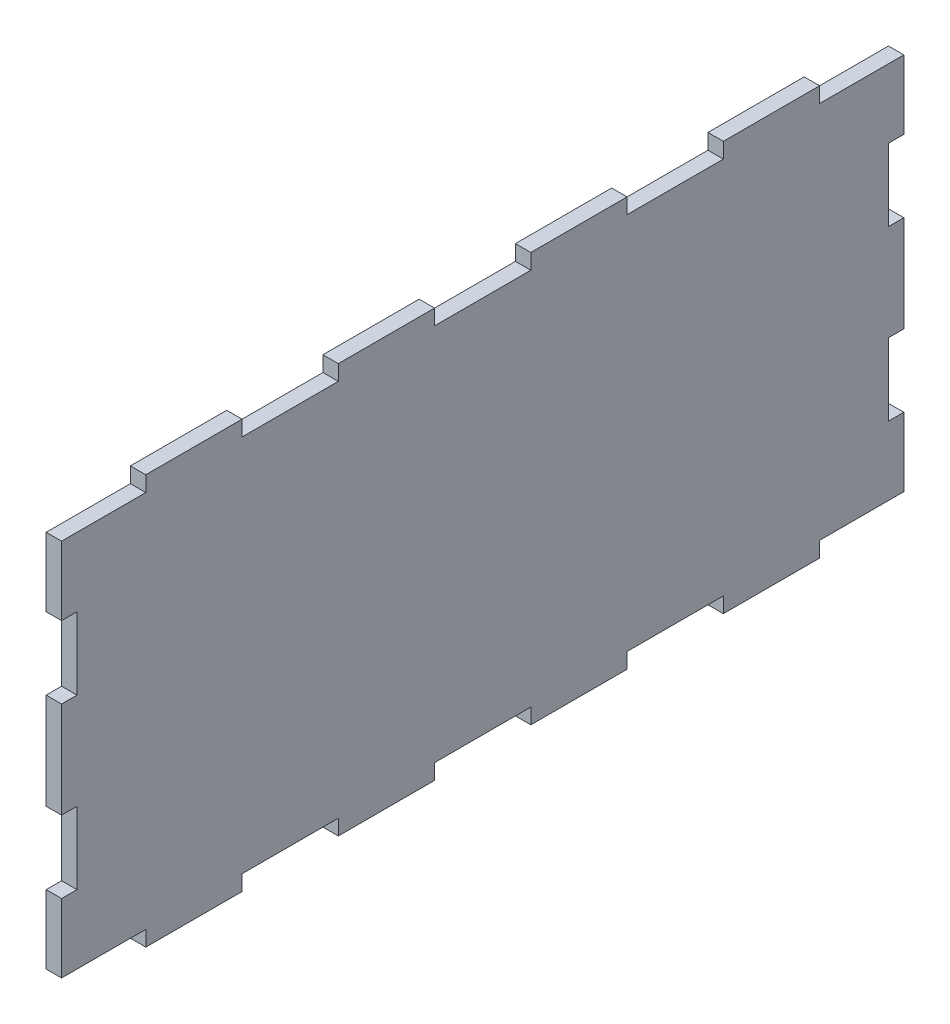
from build123d import *

# Parameters (mm, degrees)
BOSS_EXTRUDE1_DEPTH = 3.2


with BuildPart() as part:
    # Sketch1 → Boss-Extrude1 (new body)
    with BuildSketch(Plane(origin=(0, 0, 0), x_dir=(0, 0, -1), z_dir=(1, 0, 0))):
        Polygon((-10, 42.5), (-30, 42.5), (-30, 39.3), (-50, 39.3), (-50, 42.5), (-70, 42.5), (-70, 39.3), (-87.5, 39.3), (-87.5, 25), (-84.3, 25), (-84.3, 10), (-87.5, 10), (-87.5, -10), (-84.3, -10), (-84.3, -25), (-87.5, -25), (-87.5, -39.3), (-70, -39.3), (-70, -42.5), (-50, -42.5), (-50, -39.3), (-30, -39.3), (-30, -42.5), (-10, -42.5), (-10, -39.3), (10, -39.3), (10, -42.5), (30, -42.5), (30, -39.3), (50, -39.3), (50, -42.5), (70, -42.5), (70, -39.3), (87.5, -39.3), (87.5, -25), (84.3, -25), (84.3, -10), (87.5, -10), (87.5, 10), (84.3, 10), (84.3, 25), (87.5, 25), (87.5, 39.3), (70, 39.3), (70, 42.5), (50, 42.5), (50, 39.3), (30, 39.3), (30, 42.5), (10, 42.5), (10, 39.3), (-10, 39.3), align=None)
    extrude(amount=BOSS_EXTRUDE1_DEPTH)


solid = part.part
